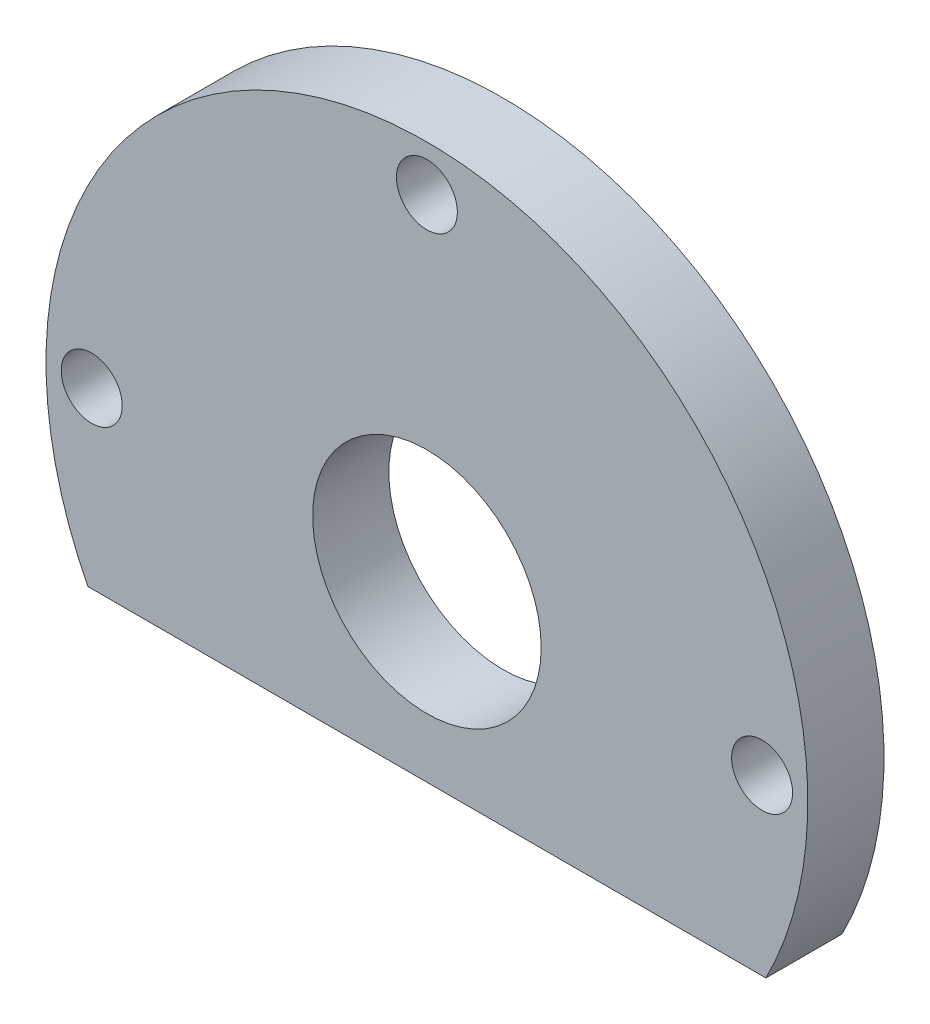
from build123d import *

# Parameters (mm, degrees)
SKETCH1_R           = 25
SKETCH1_R_2         = 7.5
BOSS_EXTRUDE1_DEPTH = 5
SKETCH2_R           = 2
CUT_EXTRUDE1_DEPTH  = 5


with BuildPart() as part:
    # Sketch1 → Boss-Extrude1 (new body)
    with BuildSketch(Plane.XY):
        Circle(SKETCH1_R)
        Circle(SKETCH1_R_2, mode=Mode.SUBTRACT)
    extrude(amount=BOSS_EXTRUDE1_DEPTH)

    # Sketch2 → Cut-Extrude1 (cut)
    with BuildSketch(Plane.XY.offset(5)):
        with Locations((0, 22)):
            Circle(SKETCH2_R)
        with Locations((22, 0)):
            Circle(SKETCH2_R)
        with Locations((-22, 0)):
            Circle(SKETCH2_R)
        with BuildLine():
            Line((-22.24968915, -11.39961985), (22.24968915, -11.39961985))
            ThreePointArc((22.24968915, -11.39961985), (0, -25), (-22.24968915, -11.39961985))
        make_face()
    extrude(amount=-CUT_EXTRUDE1_DEPTH, mode=Mode.SUBTRACT)


solid = part.part
